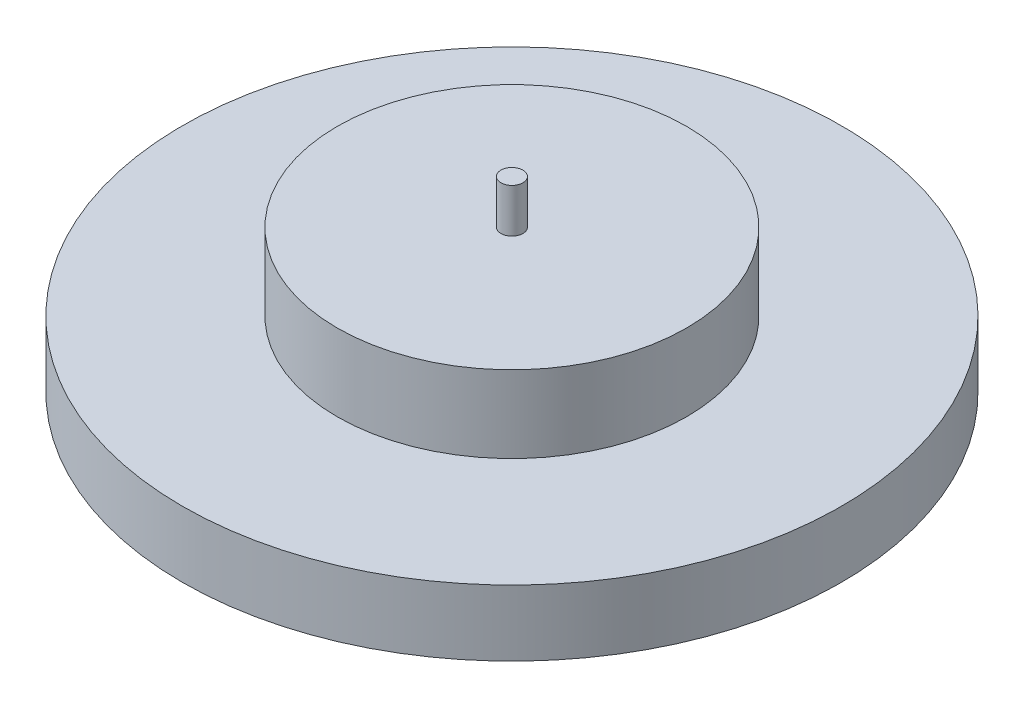
from build123d import *

# Parameters (mm, degrees)
SKETCH_1_R      = 15
EXTRUDE_1_DEPTH = 3
SKETCH_2_R      = 7.95
EXTRUDE_2_DEPTH = 3.5
SKETCH_3_R      = 0.5
EXTRUDE_3_DEPTH = 2


with BuildPart() as part:
    # 草图1 → 凸台-拉伸1 (new body)
    with BuildSketch(Plane(origin=(0, 0, 0), x_dir=(1, 0, 0), z_dir=(0, 1, 0))):
        Circle(SKETCH_1_R)
    extrude(amount=EXTRUDE_1_DEPTH)

    # 草图2 → 凸台-拉伸2 (add)
    with BuildSketch(Plane(origin=(0, 3, 0), x_dir=(1, 0, 0), z_dir=(0, 1, 0))):
        Circle(SKETCH_2_R)
    extrude(amount=EXTRUDE_2_DEPTH)

    # 草图3 → 凸台-拉伸3 (add)
    with BuildSketch(Plane(origin=(0, 6.5, 0), x_dir=(1, 0, 0), z_dir=(0, 1, 0))):
        Circle(SKETCH_3_R)
    extrude(amount=EXTRUDE_3_DEPTH)


solid = part.part
